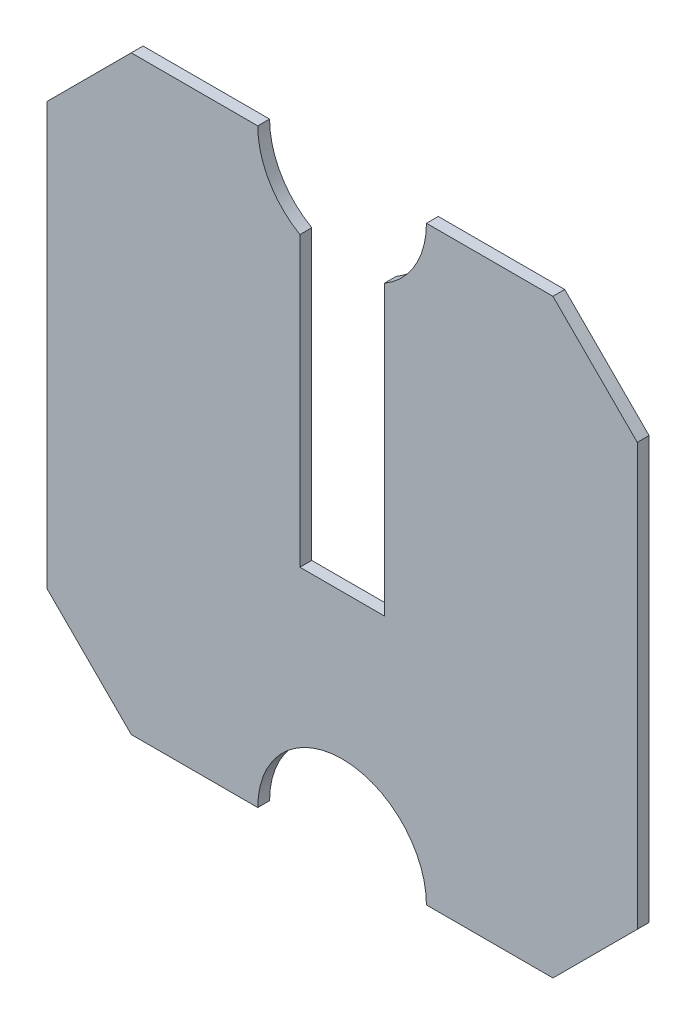
from build123d import *

# Parameters (mm, degrees)
BOSS_EXTRUDE1_DEPTH = 7
SKETCH3_W           = 50
SKETCH3_H           = 212.444289875
CUT_EXTRUDE2_DEPTH  = 8


with BuildPart() as part:
    # Sketch1 → Boss-Extrude1 (new body)
    with BuildSketch(Plane.XY):
        with BuildLine():
            Line((0, 0), (0, 250))
            Line((0, 250), (50, 300))
            Line((50, 300), (125, 300))
            ThreePointArc((125, 300), (175, 250), (225, 300))
            Line((225, 300), (300, 300))
            Line((300, 300), (350, 250))
            Line((350, 250), (350, 0))
            Line((350, 0), (300, -50))
            Line((300, -50), (225, -50))
            ThreePointArc((225, -50), (175, 0), (125, -50))
            Line((125, -50), (50, -50))
            Line((50, -50), (0, 0))
        make_face()
    extrude(amount=BOSS_EXTRUDE1_DEPTH)

    # Sketch3 → Cut-Extrude2 (cut, through all)
    with BuildSketch(Plane.XY.offset(7)):
        with Locations((175, 192.120840959)):
            Rectangle(SKETCH3_W, SKETCH3_H)
    extrude(amount=-CUT_EXTRUDE2_DEPTH, mode=Mode.SUBTRACT)


solid = part.part
